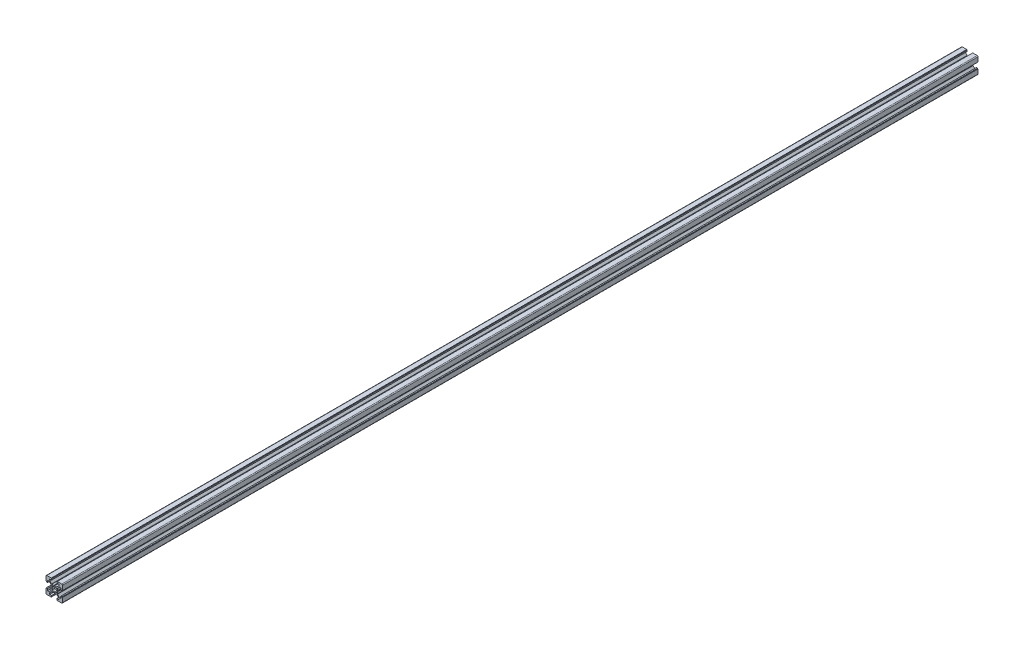
from build123d import *

# Parameters (mm, degrees)
EXTRUDE1_DEPTH = 1110


with BuildPart() as part:
    # Sketch1 → Extrude1 (new body)
    with BuildSketch(Plane.XY):
        with BuildLine():
            Line((0, 3.4), (-0.5, 3.9))
            Line((-0.5, 3.9), (-2.844365081, 3.9))
            ThreePointArc((-2.844365081, 3.9), (-3.035706798, 3.938060234), (-3.197918472, 4.046446609))
            Line((-3.197918472, 4.046446609), (-5.5, 6.348528137))
            Line((-5.5, 6.348528137), (-5.5, 8.1))
            Line((-5.5, 8.1), (-3.1, 8.1))
            Line((-3.1, 8.1), (-3.1, 9.5))
            Line((-3.1, 9.5), (-3.4, 9.5))
            ThreePointArc((-3.4, 9.5), (-3.541421356, 9.558578644), (-3.6, 9.7))
            Line((-3.6, 9.7), (-3.6, 10))
            Line((-3.6, 10), (-9, 10))
            ThreePointArc((-9, 10), (-9.707106781, 9.707106781), (-10, 9))
            Line((-10, 9), (-10, 3.6))
            Line((-10, 3.6), (-9.7, 3.6))
            ThreePointArc((-9.7, 3.6), (-9.558578644, 3.541421356), (-9.5, 3.4))
            Line((-9.5, 3.4), (-9.5, 3.1))
            Line((-9.5, 3.1), (-8.1, 3.1))
            Line((-8.1, 3.1), (-8.1, 5.5))
            Line((-8.1, 5.5), (-6.348528137, 5.5))
            Line((-6.348528137, 5.5), (-4.046446609, 3.197918472))
            ThreePointArc((-4.046446609, 3.197918472), (-3.938060234, 3.035706798), (-3.9, 2.844365081))
            Line((-3.9, 2.844365081), (-3.9, 0.5))
            Line((-3.9, 0.5), (-3.4, 0))
            Line((-3.4, 0), (-3.9, -0.5))
            Line((-3.9, -0.5), (-3.9, -2.844365081))
            ThreePointArc((-3.9, -2.844365081), (-3.938060234, -3.035706798), (-4.046446609, -3.197918472))
            Line((-4.046446609, -3.197918472), (-6.348528137, -5.5))
            Line((-6.348528137, -5.5), (-8.1, -5.5))
            Line((-8.1, -5.5), (-8.1, -3.1))
            Line((-8.1, -3.1), (-9.5, -3.1))
            Line((-9.5, -3.1), (-9.5, -3.4))
            ThreePointArc((-9.5, -3.4), (-9.558578644, -3.541421356), (-9.7, -3.6))
            Line((-9.7, -3.6), (-10, -3.6))
            Line((-10, -3.6), (-10, -9))
            ThreePointArc((-10, -9), (-9.707106781, -9.707106781), (-9, -10))
            Line((-9, -10), (-3.6, -10))
            Line((-3.6, -10), (-3.6, -9.7))
            ThreePointArc((-3.6, -9.7), (-3.541421356, -9.558578644), (-3.4, -9.5))
            Line((-3.4, -9.5), (-3.1, -9.5))
            Line((-3.1, -9.5), (-3.1, -8.1))
            Line((-3.1, -8.1), (-5.5, -8.1))
            Line((-5.5, -8.1), (-5.5, -6.348528137))
            Line((-5.5, -6.348528137), (-3.197918472, -4.046446609))
            ThreePointArc((-3.197918472, -4.046446609), (-3.035706798, -3.938060234), (-2.844365081, -3.9))
            Line((-2.844365081, -3.9), (-0.5, -3.9))
            Line((-0.5, -3.9), (0, -3.4))
            Line((0, -3.4), (0.5, -3.9))
            Line((0.5, -3.9), (2.844365081, -3.9))
            ThreePointArc((2.844365081, -3.9), (3.035706798, -3.938060234), (3.197918472, -4.046446609))
            Line((3.197918472, -4.046446609), (5.5, -6.348528137))
            Line((5.5, -6.348528137), (5.5, -8.1))
            Line((5.5, -8.1), (3.1, -8.1))
            Line((3.1, -8.1), (3.1, -9.5))
            Line((3.1, -9.5), (3.4, -9.5))
            ThreePointArc((3.4, -9.5), (3.541421356, -9.558578644), (3.6, -9.7))
            Line((3.6, -9.7), (3.6, -10))
            Line((3.6, -10), (9, -10))
            ThreePointArc((9, -10), (9.707106781, -9.707106781), (10, -9))
            Line((10, -9), (10, -3.6))
            Line((10, -3.6), (9.7, -3.6))
            ThreePointArc((9.7, -3.6), (9.558578644, -3.541421356), (9.5, -3.4))
            Line((9.5, -3.4), (9.5, -3.1))
            Line((9.5, -3.1), (8.1, -3.1))
            Line((8.1, -3.1), (8.1, -5.5))
            Line((8.1, -5.5), (6.348528137, -5.5))
            Line((6.348528137, -5.5), (4.046446609, -3.197918472))
            ThreePointArc((4.046446609, -3.197918472), (3.938060234, -3.035706798), (3.9, -2.844365081))
            Line((3.9, -2.844365081), (3.9, -0.5))
            Line((3.9, -0.5), (3.4, 0))
            Line((3.4, 0), (3.9, 0.5))
            Line((3.9, 0.5), (3.9, 2.844365081))
            ThreePointArc((3.9, 2.844365081), (3.938060234, 3.035706798), (4.046446609, 3.197918472))
            Line((4.046446609, 3.197918472), (6.348528137, 5.5))
            Line((6.348528137, 5.5), (8.1, 5.5))
            Line((8.1, 5.5), (8.1, 3.1))
            Line((8.1, 3.1), (9.5, 3.1))
            Line((9.5, 3.1), (9.5, 3.4))
            ThreePointArc((9.5, 3.4), (9.558578644, 3.541421356), (9.7, 3.6))
            Line((9.7, 3.6), (10, 3.6))
            Line((10, 3.6), (10, 9))
            ThreePointArc((10, 9), (9.707106781, 9.707106781), (9, 10))
            Line((9, 10), (3.6, 10))
            Line((3.6, 10), (3.6, 9.7))
            ThreePointArc((3.6, 9.7), (3.541421356, 9.558578644), (3.4, 9.5))
            Line((3.4, 9.5), (3.1, 9.5))
            Line((3.1, 9.5), (3.1, 8.1))
            Line((3.1, 8.1), (5.5, 8.1))
            Line((5.5, 8.1), (5.5, 6.348528137))
            Line((5.5, 6.348528137), (3.197918472, 4.046446609))
            ThreePointArc((3.197918472, 4.046446609), (3.035706798, 3.938060234), (2.844365081, 3.9))
            Line((2.844365081, 3.9), (0.5, 3.9))
            Line((0.5, 3.9), (0, 3.4))
        make_face()
        with BuildLine():
            ThreePointArc((2.5, 0), (2.394160656, -0.719718523), (2.085604198, -1.378497417))
            Line((2.085604198, -1.378497417), (2.828427125, -2.121320344))
            Line((2.828427125, -2.121320344), (2.121320344, -2.828427125))
            Line((2.121320344, -2.828427125), (1.378497417, -2.085604198))
            ThreePointArc((1.378497417, -2.085604198), (0, -2.5), (-1.378497417, -2.085604198))
            Line((-1.378497417, -2.085604198), (-2.121320344, -2.828427125))
            Line((-2.121320344, -2.828427125), (-2.828427125, -2.121320344))
            Line((-2.828427125, -2.121320344), (-2.085604198, -1.378497417))
            ThreePointArc((-2.085604198, -1.378497417), (-2.5, 0), (-2.085604198, 1.378497417))
            Line((-2.085604198, 1.378497417), (-2.828427125, 2.121320344))
            Line((-2.828427125, 2.121320344), (-2.121320344, 2.828427125))
            Line((-2.121320344, 2.828427125), (-1.378497417, 2.085604198))
            ThreePointArc((-1.378497417, 2.085604198), (0, 2.5), (1.378497417, 2.085604198))
            Line((1.378497417, 2.085604198), (2.121320344, 2.828427125))
            Line((2.121320344, 2.828427125), (2.828427125, 2.121320344))
            Line((2.828427125, 2.121320344), (2.085604198, 1.378497417))
            ThreePointArc((2.085604198, 1.378497417), (2.394160656, 0.719718523), (2.5, 0))
        make_face(mode=Mode.SUBTRACT)
    extrude(amount=EXTRUDE1_DEPTH)


solid = part.part
